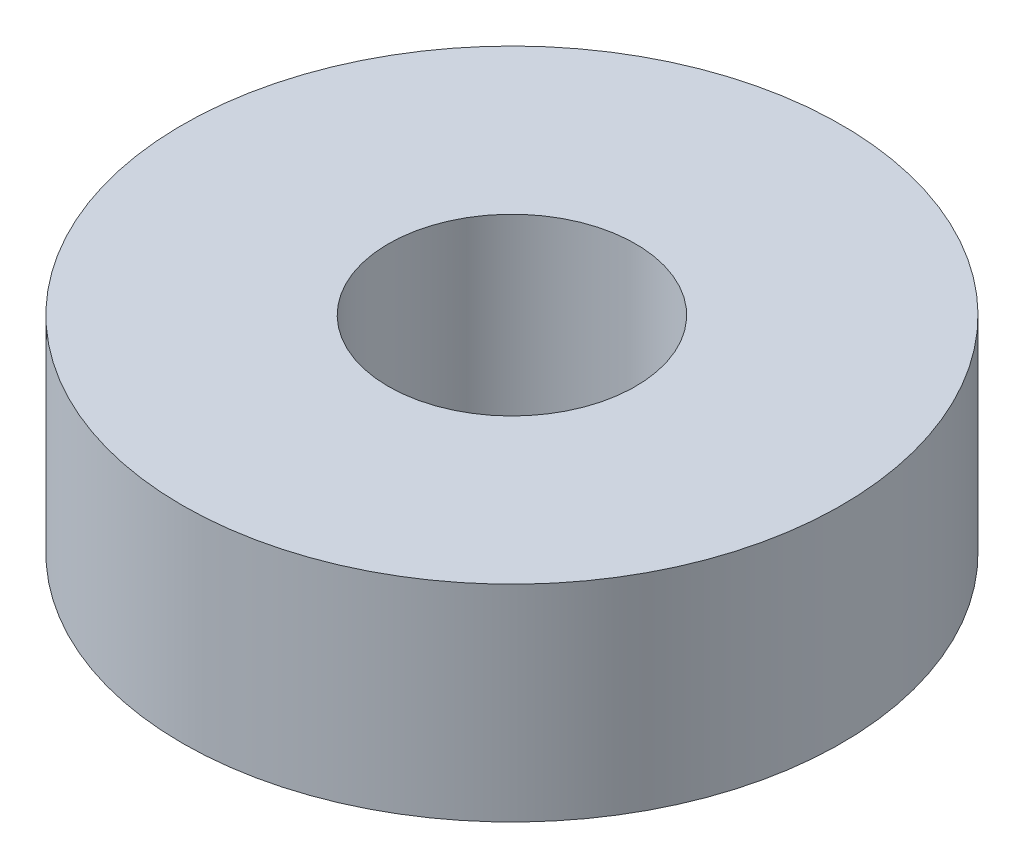
from build123d import *

# Parameters (mm, degrees)
SKETCH_1_R      = 4
SKETCH_1_R_2    = 1.5
EXTRUDE_1_DEPTH = 2.5


with BuildPart() as part:
    # 草图1 → 凸台-拉伸1 (new body)
    with BuildSketch(Plane(origin=(0, 0, 0), x_dir=(1, 0, 0), z_dir=(0, 1, 0))):
        Circle(SKETCH_1_R)
        Circle(SKETCH_1_R_2, mode=Mode.SUBTRACT)
    extrude(amount=EXTRUDE_1_DEPTH)


solid = part.part
